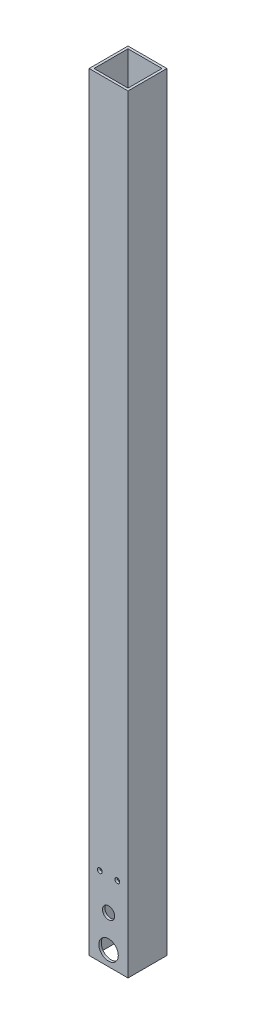
from build123d import *

# Parameters (mm, degrees)
SKETCH1_W           = 25.4
SKETCH1_H           = 25.4
SKETCH1_W_2         = 22.225
SKETCH1_H_2         = 22.225
BOSS_EXTRUDE1_DEPTH = 501.65
SKETCH4_R           = 6.35
CUT_EXTRUDE1_DEPTH  = 26.4
SKETCH5_R           = 1.5875
CUT_EXTRUDE2_DEPTH  = 26.4
SKETCH7_R           = 3.96875
CUT_EXTRUDE3_DEPTH  = 1.5875


with BuildPart() as part:
    # Sketch1 → Boss-Extrude1 (new body)
    with BuildSketch(Plane(origin=(0, 0, 0), x_dir=(1, 0, 0), z_dir=(0, 1, 0))):
        Rectangle(SKETCH1_W, SKETCH1_H)
        Rectangle(SKETCH1_W_2, SKETCH1_H_2, mode=Mode.SUBTRACT)
    extrude(amount=BOSS_EXTRUDE1_DEPTH)

    # Sketch4 → Cut-Extrude1 (cut, through all)
    with BuildSketch(Plane.XY.offset(12.7)):
        with Locations((0, 9.525)):
            Circle(SKETCH4_R)
    extrude(amount=-CUT_EXTRUDE1_DEPTH, mode=Mode.SUBTRACT)

    # Sketch5 → Cut-Extrude2 (cut, through all)
    with BuildSketch(Plane(origin=(0, 0, -12.7), x_dir=(-1, 0, 0), z_dir=(0, 0, -1))):
        with Locations((-5.709637497, 51.517813992)):
            Circle(SKETCH5_R)
        with Locations((5.709637497, 51.517813992)):
            Circle(SKETCH5_R)
    extrude(amount=-CUT_EXTRUDE2_DEPTH, mode=Mode.SUBTRACT)

    # Sketch7 → Cut-Extrude3 (cut)
    with BuildSketch(Plane.XY.offset(12.7)):
        with Locations((0, 30.5023012)):
            Circle(SKETCH7_R)
    extrude(amount=-CUT_EXTRUDE3_DEPTH, mode=Mode.SUBTRACT)


solid = part.part
